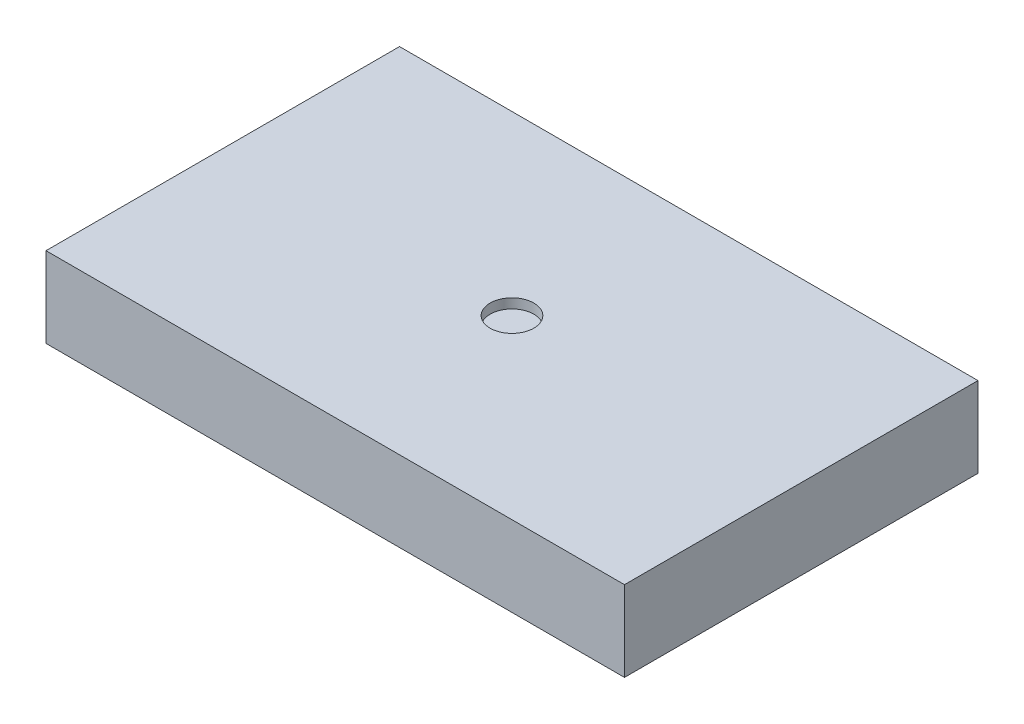
from build123d import *

# Parameters (mm, degrees)
SKETCH1_W           = 45.72
SKETCH1_H           = 27.94
BOSS_EXTRUDE1_DEPTH = 6.35
SKETCH2_R           = 1.724843726
CUT_EXTRUDE1_DEPTH  = 0.762


with BuildPart() as part:
    # Sketch1 → Boss-Extrude1 (new body)
    with BuildSketch(Plane(origin=(0, 0, 0), x_dir=(1, 0, 0), z_dir=(0, 1, 0))):
        Rectangle(SKETCH1_W, SKETCH1_H)
    extrude(amount=BOSS_EXTRUDE1_DEPTH)

    # Sketch2 → Cut-Extrude1 (cut)
    with BuildSketch(Plane(origin=(0, 6.35, 0), x_dir=(1, 0, 0), z_dir=(0, 1, 0))):
        Circle(SKETCH2_R)
    extrude(amount=-CUT_EXTRUDE1_DEPTH, mode=Mode.SUBTRACT)


solid = part.part
